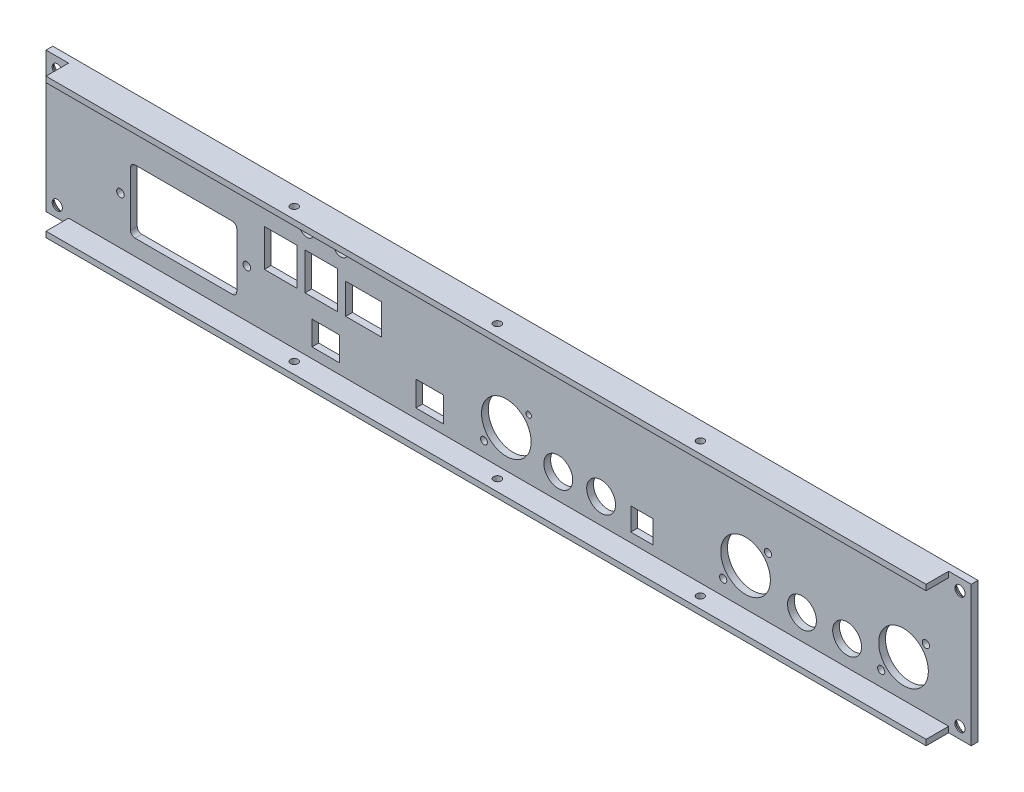
from build123d import *

# Parameters (mm, degrees)
SKETCH_1_W                  = 410
SKETCH_1_H                  = 62
EXTRUDE_1_DEPTH             = 3
HOLE_WIZARD_M4_1_AT_2_COUNT = 2
HOLE_WIZARD_M4_1_AT_2_PITCH = 52
HOLE_WIZARD_M4_1_AT_3_COUNT = 2
HOLE_WIZARD_M4_1_AT_3_PITCH = 403.365838911
HOLE_WIZARD_M4_1_AT_4_COUNT = 2
HOLE_WIZARD_M4_1_AT_4_PITCH = 400
SKETCH_5_W                  = 390
SKETCH_5_H                  = 2.5
EXTRUDE_2_DEPTH             = 10
SKETCH_6_R                  = 1.7
SKETCH_6_W                  = 15.9
SKETCH_6_H                  = 13.5
SKETCH_6_W_2                = 14.5
SKETCH_6_H_2                = 16.5
SKETCH_6_W_3                = 12.3
SKETCH_6_H_3                = 10.7
SKETCH_6_H_4                = 11.1
SKETCH_6_R_2                = 11
SKETCH_6_R_3                = 1.217933171
SKETCH_6_R_4                = 6.4
SKETCH_6_R_5                = 1.507896367
SKETCH_6_W_4                = 9.75
SKETCH_6_H_5                = 10.05
SKETCH_6_R_6                = 1.6
SKETCH_6_R_7                = 3.25
CUT_EXTRUDE_1_DEPTH         = 10
HOLE_WIZARD_M4_1_2_D        = 3.3


with BuildPart() as part:
    # 草圖1 → 填料-伸長1 (new body)
    with BuildSketch(Plane.XY):
        Rectangle(SKETCH_1_W, SKETCH_1_H)
    extrude(amount=EXTRUDE_1_DEPTH)

    # 草圖2 → Hole Wizard M4 _1 (revolve, cut)
    with BuildSketch(Plane(origin=(-200, 26, 0), x_dir=(0, 1, 0), z_dir=(1, 0, 0))):
        Polygon((0, 0), (0, 3), (2.25, 3), (2.25, 2.45), (4.7, 0), align=None)
    hole_wizard_m4_1 = revolve(axis=Axis((-200, 26, -6.35), (0, 0, 1)), mode=Mode.SUBTRACT)

    # Hole Wizard M4 _1 at 2: Hole Wizard M4 _1 ×2
    with Locations(*[(0, -i * HOLE_WIZARD_M4_1_AT_2_PITCH, 0) for i in range(1, HOLE_WIZARD_M4_1_AT_2_COUNT)]):
        add(hole_wizard_m4_1, mode=Mode.SUBTRACT)

    # Hole Wizard M4 _1 at 3: Hole Wizard M4 _1 ×2
    with Locations(*[Vector(0.991655617, -0.12891523, 0) * (i * HOLE_WIZARD_M4_1_AT_3_PITCH) for i in range(1, HOLE_WIZARD_M4_1_AT_3_COUNT)]):
        add(hole_wizard_m4_1, mode=Mode.SUBTRACT)

    # Hole Wizard M4 _1 at 4: Hole Wizard M4 _1 ×2
    with Locations(*[(i * HOLE_WIZARD_M4_1_AT_4_PITCH, 0, 0) for i in range(1, HOLE_WIZARD_M4_1_AT_4_COUNT)]):
        add(hole_wizard_m4_1, mode=Mode.SUBTRACT)

    # 草圖5 → 填料-伸長2 (add)
    with BuildSketch(Plane.XY.offset(3)):
        with Locations((0, 29.75)):
            Rectangle(SKETCH_5_W, SKETCH_5_H)
        with Locations((0, -29.75)):
            Rectangle(SKETCH_5_W, SKETCH_5_H)
    extrude(amount=EXTRUDE_2_DEPTH)

    # 草圖6 → 除料-伸長1 (cut)
    with BuildSketch(Plane.XY.offset(3)):
        with BuildLine():
            ThreePointArc((-167.568, 4.65), (-166.982213562, 6.064213562), (-165.568, 6.65))
            Line((-165.568, 6.65), (-122.468, 6.65))
            ThreePointArc((-122.468, 6.65), (-121.053786438, 6.064213562), (-120.468, 4.65))
            Line((-120.468, 4.65), (-120.468, -19.45))
            ThreePointArc((-120.468, -19.45), (-121.053786438, -20.864213562), (-122.468, -21.45))
            Line((-122.468, -21.45), (-165.568, -21.45))
            ThreePointArc((-165.568, -21.45), (-166.982213562, -20.864213562), (-167.568, -19.45))
            Line((-167.568, -19.45), (-167.568, 4.65))
        make_face()
        with Locations((-172.018, -7.4)):
            Circle(SKETCH_6_R)
        with Locations((-116.018, -7.4)):
            Circle(SKETCH_6_R)
        with Locations((-64.268, 1.95)):
            Rectangle(SKETCH_6_W, SKETCH_6_H)
        with Locations((-83.018, 3.45)):
            Rectangle(SKETCH_6_W_2, SKETCH_6_H_2)
        with Locations((-101.018, 3.45)):
            Rectangle(SKETCH_6_W_2, SKETCH_6_H_2)
        with Locations((-81.018, -18.65)):
            Rectangle(SKETCH_6_W_3, SKETCH_6_H_3)
        with Locations((-34.9934, -18.85)):
            Rectangle(SKETCH_6_W_3, SKETCH_6_H_4)
        with Locations((-1.0082, -11.9)):
            Circle(SKETCH_6_R_2)
        with Locations((8.8918, -2)):
            Circle(SKETCH_6_R_3)
        with Locations((22.0042, -17.35)):
            Circle(SKETCH_6_R_4)
        with Locations((-10.9082, -21.8)):
            Circle(SKETCH_6_R_5)
        with Locations((59.012, -19.375)):
            Rectangle(SKETCH_6_W_4, SKETCH_6_H_5)
        with Locations((41.0034, -17.35)):
            Circle(SKETCH_6_R_4)
        with Locations((105, -11.9)):
            Circle(SKETCH_6_R_2)
        with Locations((130, -17.35)):
            Circle(SKETCH_6_R_4)
        with Locations((150, -17.35)):
            Circle(SKETCH_6_R_4)
        with Locations((175, -11.9)):
            Circle(SKETCH_6_R_2)
        with Locations((184.9, -2)):
            Circle(SKETCH_6_R_6)
        with Locations((165.1, -21.8)):
            Circle(SKETCH_6_R_6)
        with Locations((114.9, -2)):
            Circle(SKETCH_6_R_6)
        with Locations((95.1, -21.8)):
            Circle(SKETCH_6_R_6)
        with Locations((-74.365709963, 20.2)):
            Circle(SKETCH_6_R_7)
        with Locations((-89.365709963, 20.2)):
            Circle(SKETCH_6_R_7)
    extrude(amount=-CUT_EXTRUDE_1_DEPTH, mode=Mode.SUBTRACT)

    # Hole Wizard M4 _1 2 (through all)
    with Locations(Plane(origin=(0, 31, 0), x_dir=(1, 0, 0), z_dir=(0, 1, 0))):
        with Locations((0, -8), (-90, -8), (90, -8)):
            Hole(HOLE_WIZARD_M4_1_2_D / 2)


solid = part.part
